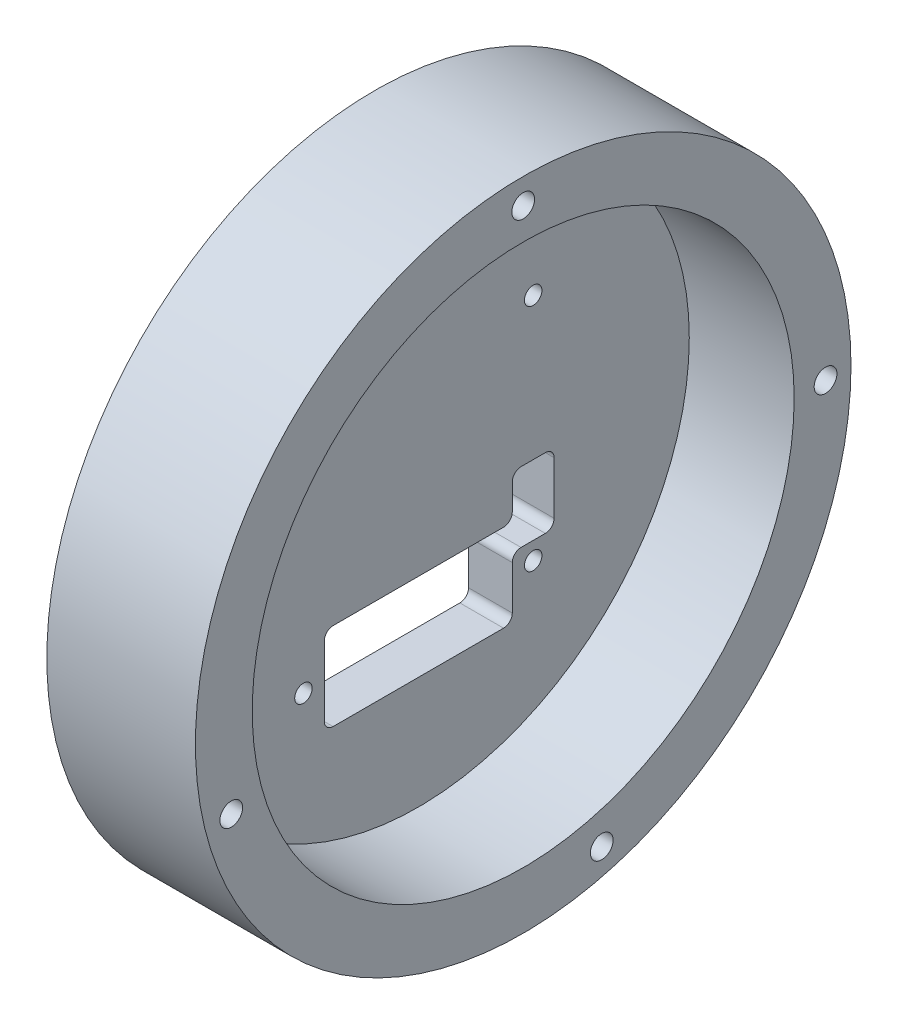
from build123d import *

# Parameters (mm, degrees)
SKETCH1_R               = 37.5
BOSS_EXTRUDE1_DEPTH     = 5
SKETCH3_R               = 1
CUT_EXTRUDE2_DEPTH      = 6
SKETCH4_R               = 37.5
SKETCH4_R_2             = 31
BOSS_EXTRUDE2_DEPTH     = 12
SKETCH2_R               = 1.3
CUT_EXTRUDE1_DEPTH      = 13
CUT_EXTRUDE1_DEPTH_BACK = 6
CUT_EXTRUDE3_DEPTH      = 6


with BuildPart() as part:
    # Sketch1 → Boss-Extrude1 (new body)
    with BuildSketch(Plane(origin=(0, 0, 0), x_dir=(0, 0, -1), z_dir=(1, 0, 0))):
        Circle(SKETCH1_R)
    extrude(amount=BOSS_EXTRUDE1_DEPTH)

    # Sketch3 → Cut-Extrude2 (cut, through all)
    with BuildSketch(Plane.ZY):
        with Locations((-13.14, 13.14)):
            Circle(SKETCH3_R)
        with Locations((13.14, 13.14)):
            Circle(SKETCH3_R)
        with Locations((13.14, -13.14)):
            Circle(SKETCH3_R)
        with Locations((-13.14, -13.14)):
            Circle(SKETCH3_R)
    extrude(amount=-CUT_EXTRUDE2_DEPTH, mode=Mode.SUBTRACT)

    # Sketch4 → Boss-Extrude2 (add)
    with BuildSketch(Plane(origin=(5, 0, 0), x_dir=(0, 0, -1), z_dir=(1, 0, 0))):
        Circle(SKETCH4_R)
        Circle(SKETCH4_R_2, mode=Mode.SUBTRACT)
    extrude(amount=BOSS_EXTRUDE2_DEPTH)

    # Sketch2 → Cut-Extrude1 (cut, two sides)
    with BuildSketch(Plane(origin=(5, 0, 0), x_dir=(0, 0, -1), z_dir=(1, 0, 0))) as cut_extrude1_sk:
        with Locations((0, 34.588098227)):
            Circle(SKETCH2_R)
        with Locations((8.984441127, -33.400843651)):
            Circle(SKETCH2_R)
        with Locations((34.588098227, 0)):
            Circle(SKETCH2_R)
        with Locations((-33.400843651, -8.984441127)):
            Circle(SKETCH2_R)
    extrude(amount=CUT_EXTRUDE1_DEPTH, mode=Mode.SUBTRACT)
    extrude(cut_extrude1_sk.sketch, amount=-CUT_EXTRUDE1_DEPTH_BACK, mode=Mode.SUBTRACT)

    # Sketch5 → Cut-Extrude3 (cut, through all)
    with BuildSketch(Plane(origin=(5, 0, 0), x_dir=(0, 0, -1), z_dir=(1, 0, 0))):
        with BuildLine():
            Line((9.75, -8.14), (-9.75, -8.14))
            ThreePointArc((-9.75, -8.14), (-10.457106781, -8.432893219), (-10.75, -9.14))
            Line((-10.75, -9.14), (-10.75, -17.14))
            ThreePointArc((-10.75, -17.14), (-10.457106781, -17.847106781), (-9.75, -18.14))
            Line((-9.75, -18.14), (9.75, -18.14))
            ThreePointArc((9.75, -18.14), (10.457106781, -17.847106781), (10.75, -17.14))
            Line((10.75, -17.14), (10.75, -12.14))
            ThreePointArc((10.75, -12.14), (11.042893219, -11.432893219), (11.75, -11.14))
            Line((11.75, -11.14), (14.53, -11.14))
            ThreePointArc((14.53, -11.14), (15.237106781, -10.847106781), (15.53, -10.14))
            Line((15.53, -10.14), (15.53, -4.14))
            ThreePointArc((15.53, -4.14), (15.237106781, -3.432893219), (14.53, -3.14))
            Line((14.53, -3.14), (11.75, -3.14))
            ThreePointArc((11.75, -3.14), (11.042893219, -3.432893219), (10.75, -4.14))
            Line((10.75, -4.14), (10.75, -7.14))
            ThreePointArc((10.75, -7.14), (10.457106781, -7.847106781), (9.75, -8.14))
        make_face()
    extrude(amount=-CUT_EXTRUDE3_DEPTH, mode=Mode.SUBTRACT)


solid = part.part
